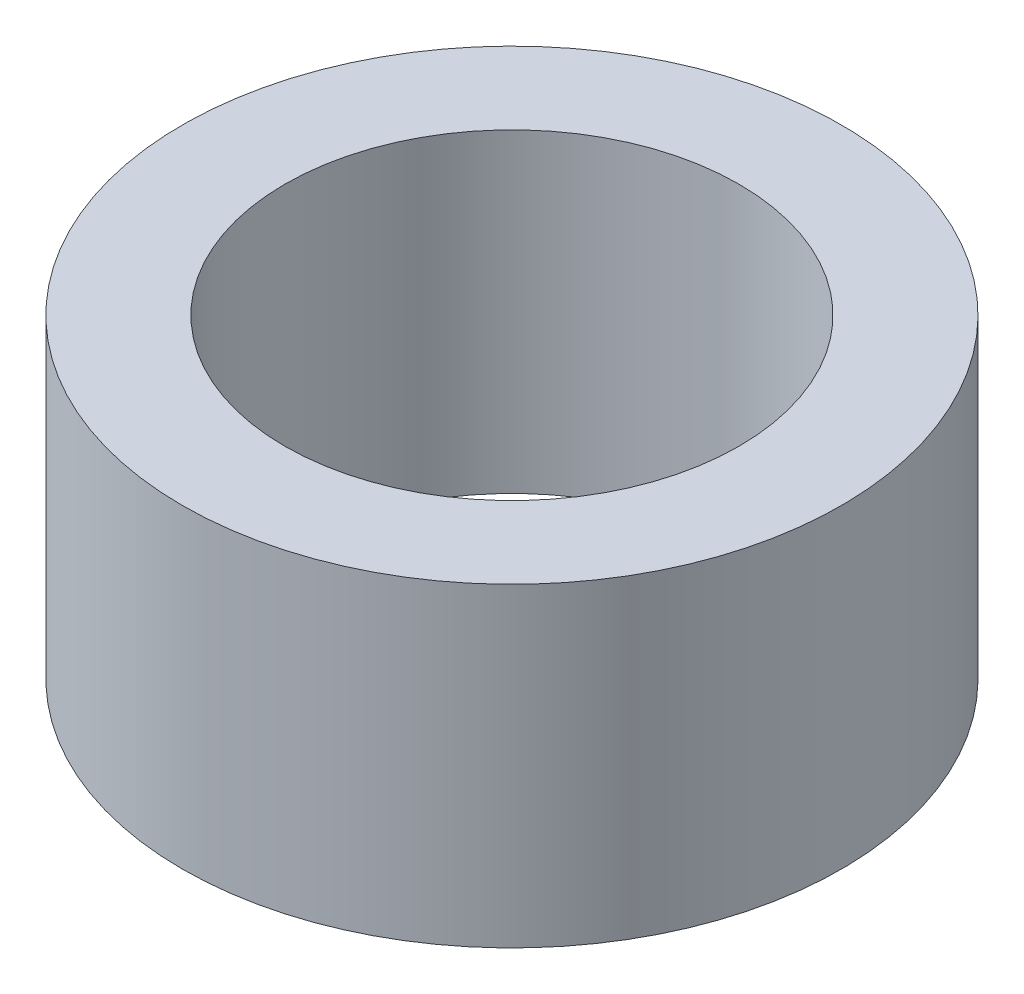
from build123d import *

# Parameters (mm, degrees)
SKETCH_1_R      = 4.5
SKETCH_1_R_2    = 3.1
EXTRUDE_1_DEPTH = 4.3


with BuildPart() as part:
    # 草图1 → 凸台-拉伸1 (new body)
    with BuildSketch(Plane(origin=(0, 0, 0), x_dir=(1, 0, 0), z_dir=(0, 1, 0))):
        Circle(SKETCH_1_R)
        Circle(SKETCH_1_R_2, mode=Mode.SUBTRACT)
    extrude(amount=EXTRUDE_1_DEPTH)


solid = part.part
